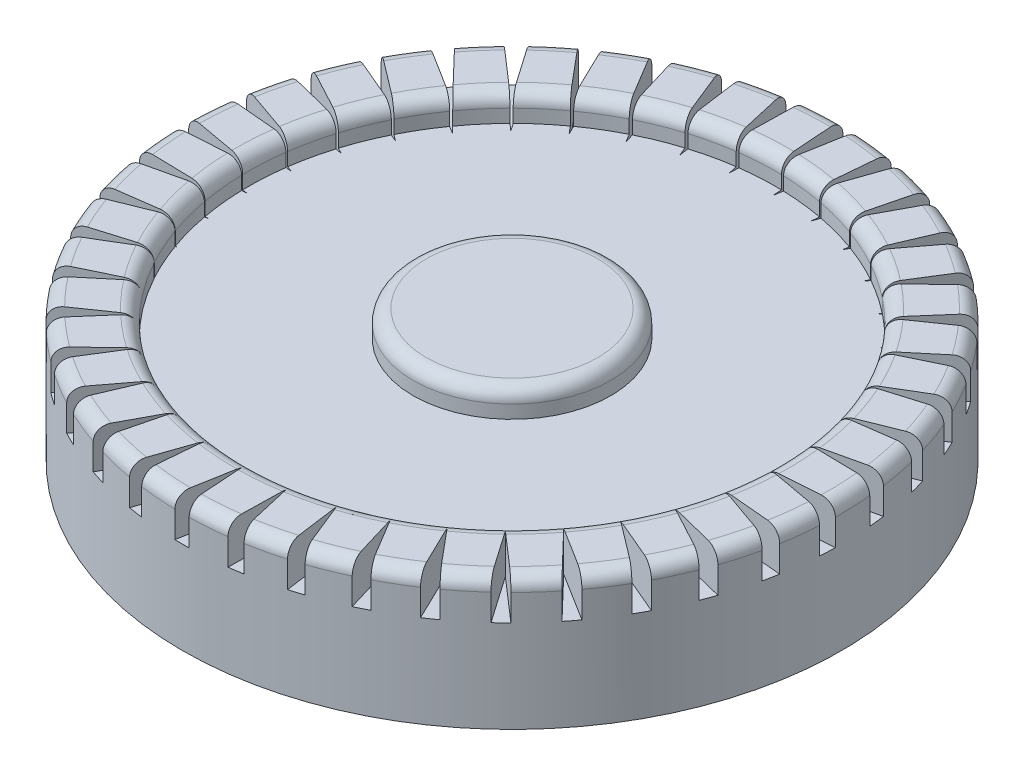
from build123d import *

# Parameters (mm, degrees)
SKETCH1_R           = 25
BOSS_EXTRUDE1_DEPTH = 10
SKETCH2_R           = 20
SKETCH2_R_2         = 7.5
CUT_EXTRUDE1_DEPTH  = 2
FILLET1_R           = 1
CUT_EXTRUDE2_DEPTH  = 3
SKETCH4_R           = 5
CUT_EXTRUDE3_DEPTH  = 0.1


with BuildPart() as part:
    # Sketch1 → Boss-Extrude1 (new body)
    with BuildSketch(Plane(origin=(0, 0, 0), x_dir=(1, 0, 0), z_dir=(0, 1, 0))):
        with Locations((-26.574324832, 27.039375516)):
            Circle(SKETCH1_R)
    extrude(amount=BOSS_EXTRUDE1_DEPTH)

    # Sketch2 → Cut-Extrude1 (cut)
    with BuildSketch(Plane(origin=(0, 10, 0), x_dir=(1, 0, 0), z_dir=(0, 1, 0))):
        with Locations((-26.574324832, 27.039375516)):
            Circle(SKETCH2_R)
        with Locations((-26.574324832, 27.039375516)):
            Circle(SKETCH2_R_2, mode=Mode.SUBTRACT)
    extrude(amount=-CUT_EXTRUDE1_DEPTH, mode=Mode.SUBTRACT)

    # Fillet1
    fillet1_edges = [part.edges().sort_by_distance(p)[0] for p in [
        (-51.574324832, 10, -27.039375516),
        (-46.574324832, 10, -27.039375516),
        (-34.074324832, 10, -27.039375516),
    ]]
    fillet(fillet1_edges, radius=FILLET1_R)

    # Sketch3 → Cut-Extrude2 (cut)
    with BuildSketch(Plane(origin=(0, 10, 0), x_dir=(1, 0, 0), z_dir=(0, 1, 0))):
        Polygon((-26.619234052, 54.149558302), (-26.08364033, 46.391372294), (-24.624190702, 54.497658222), align=None)
        Polygon((-22.272934978, 53.868778653), (-22.957582981, 46.122323471), (-20.247999098, 53.900499346), align=None)
        Polygon((-18.024069672, 52.911544897), (-19.912101094, 45.367563977), (-16.019101903, 52.626105295), align=None)
        Polygon((-13.977259299, 51.301427305), (-17.022184541, 44.145678495), (-12.041628602, 50.705855878), align=None)
        Polygon((-10.232149761, 49.078072317), (-14.358992658, 42.4867539), (-8.413517788, 48.18703401), align=None)
        Polygon((-6.880958085, 46.296226312), (-11.988102067, 40.431638423), (-5.224105589, 45.131661445), align=None)
        Polygon((-4.00620173, 43.02438757), (-9.967891965, 38.030935827), (-2.551925921, 41.614971595), align=None)
        Polygon((-1.67866674, 39.343119619), (-8.348106627, 35.343759376), (-0.462776713, 37.723557036), align=None)
        Polygon((0.044335249, 35.343067495), (-7.168630546, 32.436276274), (0.991900246, 33.553237309), align=None)
        Polygon((1.120378211, 31.122725756), (-6.458506336, 29.380078403), (1.776285983, 29.206699526), align=None)
        Polygon((1.522966396, 26.786013222), (-6.235219612, 26.250419499), (1.871066316, 24.790969872), align=None)
        Polygon((1.242186747, 22.439714148), (-6.504268435, 23.124362151), (1.27390744, 20.414778268), align=None)
        Polygon((0.284952991, 18.190848842), (-7.259027929, 20.078880264), (-0.000486611, 16.185881073), align=None)
        Polygon((-1.325164601, 14.144038469), (-8.480913411, 17.188963711), (-1.920736028, 12.208407772), align=None)
        Polygon((-3.548519589, 10.398928931), (-10.139838005, 14.525771828), (-4.439557896, 8.580296958), align=None)
        Polygon((-6.330365594, 7.047737255), (-12.194953483, 12.154881237), (-7.494930461, 5.390884759), align=None)
        Polygon((-9.602204336, 4.1729809), (-14.595656079, 10.134671135), (-11.011620311, 2.71870509), align=None)
        Polygon((-13.283472286, 1.84544591), (-17.28283253, 8.514885797), (-14.90303487, 0.629555883), align=None)
        Polygon((-17.283524411, 0.122443921), (-20.190315632, 7.335409716), (-19.073354597, -0.825121076), align=None)
        Polygon((-21.50386615, -0.953599041), (-23.246513502, 6.625285506), (-23.41989238, -1.609506813), align=None)
        Polygon((-25.840578684, -1.356187226), (-26.376172406, 6.401998782), (-27.835622034, -1.704287146), align=None)
        Polygon((-30.186877758, -1.075407577), (-29.502229755, 6.671047605), (-32.211813638, -1.10712827), align=None)
        Polygon((-34.435743064, -0.118173821), (-32.547711642, 7.425807099), (-36.440710833, 0.167265781), align=None)
        Polygon((-38.482553437, 1.491943771), (-35.437628195, 8.647692581), (-40.418184134, 2.087515198), align=None)
        Polygon((-42.227662975, 3.715298758), (-38.100820078, 10.306617175), (-44.046294948, 4.606337066), align=None)
        Polygon((-45.578854651, 6.497144764), (-40.471710669, 12.361732653), (-47.235707147, 7.661709631), align=None)
        Polygon((-48.453611006, 9.768983506), (-42.491920771, 14.762435249), (-49.907886816, 11.178399481), align=None)
        Polygon((-50.781145996, 13.450251456), (-44.111706109, 17.4496117), (-51.997036023, 15.06981404), align=None)
        Polygon((-52.504147985, 17.45030358), (-45.29118219, 20.357094802), (-53.451712982, 19.240133767), align=None)
        Polygon((-53.580190947, 21.67064532), (-46.0013064, 23.413292672), (-54.236098719, 23.58667155), align=None)
        Polygon((-53.982779132, 26.007357854), (-46.224593124, 26.542951576), (-54.330879052, 28.002401203), align=None)
        Polygon((-53.701999483, 30.353656928), (-45.955544301, 29.669008925), (-53.733720176, 32.378592808), align=None)
        Polygon((-52.744765727, 34.602522234), (-45.200784807, 32.714490812), (-52.459326125, 36.607490003), align=None)
        Polygon((-51.134648135, 38.649332607), (-43.978899325, 35.604407365), (-50.539076708, 40.584963304), align=None)
        Polygon((-48.911293148, 42.394442145), (-42.319974731, 38.267599248), (-48.02025484, 44.213074118), align=None)
        Polygon((-46.129447142, 45.745633821), (-40.264859253, 40.638489838), (-44.964882275, 47.402486317), align=None)
        Polygon((-42.8576084, 48.620390176), (-37.864156657, 42.658699941), (-41.448192425, 50.074665985), align=None)
        Polygon((-39.17634045, 50.947925166), (-35.176980206, 44.278485279), (-37.556777866, 52.163815193), align=None)
        Polygon((-35.176288325, 52.670927155), (-32.269497104, 45.45796136), (-33.386458139, 53.618492152), align=None)
        Polygon((-30.955946586, 53.746970117), (-29.213299234, 46.16808557), (-29.039920356, 54.402877889), align=None)
    extrude(amount=-CUT_EXTRUDE2_DEPTH, mode=Mode.SUBTRACT)

    # Sketch4 → Cut-Extrude3 (cut)
    with BuildSketch(Plane.XZ):
        with Locations((-26.574324832, -27.039375516)):
            Circle(SKETCH4_R)
    extrude(amount=-CUT_EXTRUDE3_DEPTH, mode=Mode.SUBTRACT)


solid = part.part
